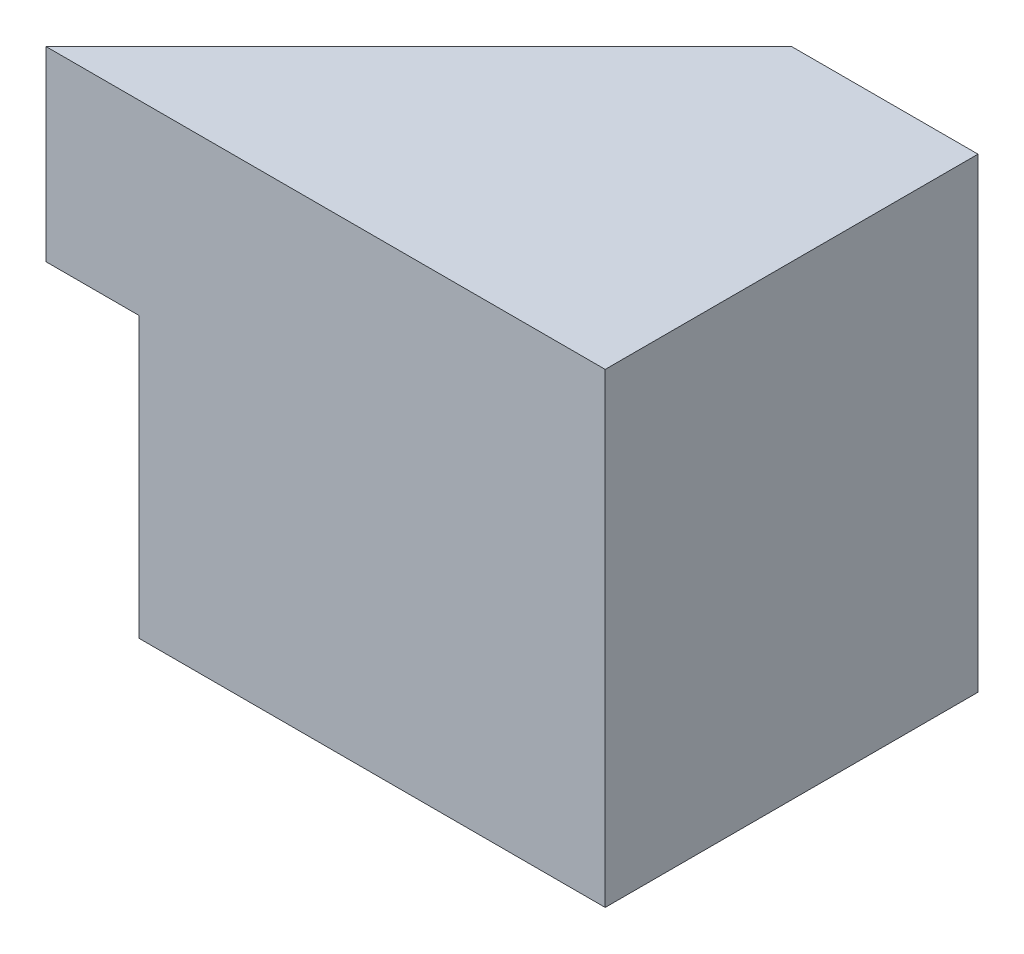
from build123d import *

# Parameters (mm, degrees)
SKETCH2_W           = 6
SKETCH2_H           = 4
BOSS_EXTRUDE1_DEPTH = 5
SKETCH3_W           = 1
SKETCH3_H           = 3
CUT_EXTRUDE1_DEPTH  = 5
CUT_EXTRUDE3_DEPTH  = 2


with BuildPart() as part:
    # Sketch2 → Boss-Extrude1 (new body)
    with BuildSketch(Plane(origin=(0, 0, 0), x_dir=(1, 0, 0), z_dir=(0, 1, 0))):
        with Locations((3, 2)):
            Rectangle(SKETCH2_W, SKETCH2_H)
    extrude(amount=BOSS_EXTRUDE1_DEPTH)

    # Sketch3 → Cut-Extrude1 (cut)
    with BuildSketch(Plane.XY):
        with Locations((0.5, 1.5)):
            Rectangle(SKETCH3_W, SKETCH3_H)
    extrude(amount=-CUT_EXTRUDE1_DEPTH, mode=Mode.SUBTRACT)

    # Sketch5 → Cut-Extrude3 (cut)
    with BuildSketch(Plane(origin=(0, 5, 0), x_dir=(1, 0, 0), z_dir=(0, 1, 0))):
        Polygon((0, 0), (4, 4), (0, 4), align=None)
    extrude(amount=-CUT_EXTRUDE3_DEPTH, mode=Mode.SUBTRACT)


solid = part.part
